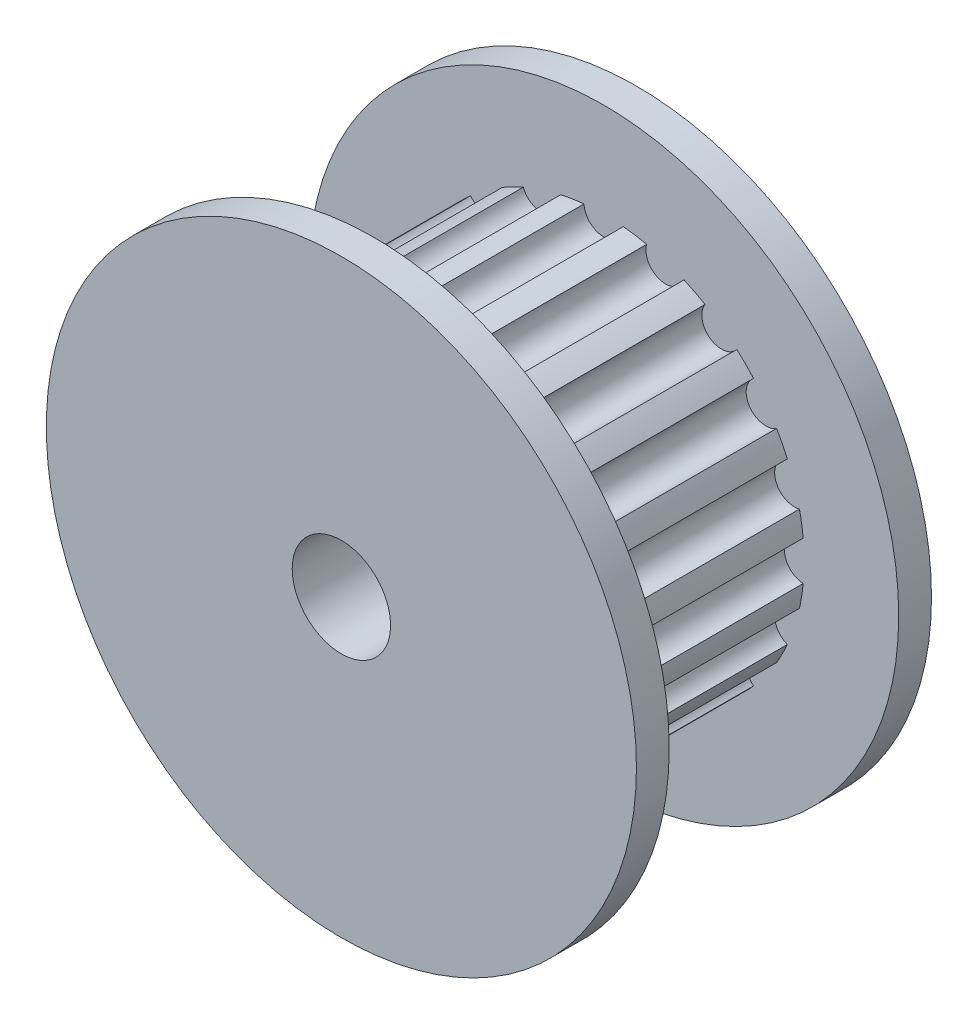
from build123d import *

# Parameters (mm, degrees)
SKETCH_1_R               = 9
EXTRUDE_1_DEPTH          = 0.5
SKETCH_2_R               = 6.115
EXTRUDE_2_DEPTH          = 7
CUT_EXTRUDE_3_DEPTH      = 7
SKETCH_3_R               = 9
EXTRUDE_3_DEPTH          = 1
SKETCH_6_R               = 1.5
CUT_EXTRUDE_2_DEPTH      = 10
PATTERN_CIRCULAR_2_COUNT = 20


with BuildPart() as part:
    # 草圖1 → 填料-伸長1 (new body, symmetric)
    with BuildSketch(Plane.XY):
        Circle(SKETCH_1_R)
    extrude(amount=EXTRUDE_1_DEPTH, both=True)

    # 草圖2 → 填料-伸長2 (add)
    with BuildSketch(Plane.XY.offset(0.5)):
        Circle(SKETCH_2_R)
    extrude(amount=EXTRUDE_2_DEPTH)

    # 草圖7 → 除料-伸長3 (cut)
    with BuildSketch(Plane.XY.offset(7.5)):
        with BuildLine():
            ThreePointArc((-0.599277509, 6.085564186), (0, 5.515), (0.599277509, 6.085564186))
            ThreePointArc((0.599277509, 6.085564186), (0, 6.115), (-0.599277509, 6.085564186))
        make_face()
    cut_extrude_3 = extrude(amount=-CUT_EXTRUDE_3_DEPTH, mode=Mode.SUBTRACT)

    # 草圖3 → 填料-伸長3 (add)
    with BuildSketch(Plane.XY.offset(7.5)):
        Circle(SKETCH_3_R)
    extrude(amount=EXTRUDE_3_DEPTH)

    # 草圖6 → 除料-伸長2 (cut, through all)
    with BuildSketch(Plane(origin=(0, 0, -0.5), x_dir=(-1, 0, 0), z_dir=(0, 0, -1))):
        Circle(SKETCH_6_R)
    extrude(amount=-CUT_EXTRUDE_2_DEPTH, mode=Mode.SUBTRACT)

    # 環狀複製排列2: 除料-伸長3 ×20 about axis
    pattern_circular_2_axis = Axis((0, 0, 0), (0, 0, 1))
    for i in range(1, PATTERN_CIRCULAR_2_COUNT):
        add(cut_extrude_3.rotate(pattern_circular_2_axis, i * 360 / PATTERN_CIRCULAR_2_COUNT), mode=Mode.SUBTRACT)


solid = part.part
